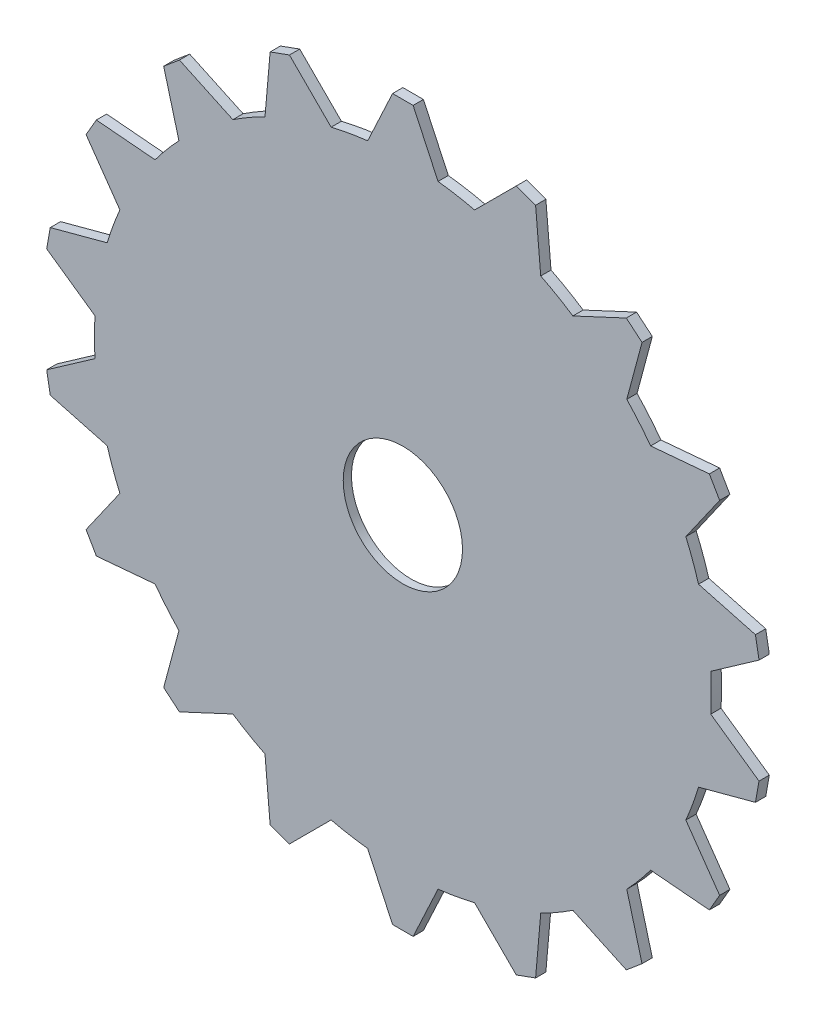
from build123d import *

# Parameters (mm, degrees)
SKETCH1_R           = 38.1
BOSS_EXTRUDE1_DEPTH = 1.27
BOSS_EXTRUDE2_DEPTH = 1.27
SKETCH3_R           = 7.366
CUT_EXTRUDE1_DEPTH  = 10
CIRPATTERN1_COUNT   = 18
SKETCH4_R           = 25.4
CUT_EXTRUDE2_DEPTH  = 0.254


with BuildPart() as part:
    # Sketch1 → Boss-Extrude1 (new body)
    with BuildSketch(Plane.XY):
        Circle(SKETCH1_R)
    extrude(amount=BOSS_EXTRUDE1_DEPTH)

    # Sketch2 → Boss-Extrude2 (add)
    with BuildSketch(Plane.XY.offset(1.27)):
        with BuildLine():
            Line((-1.27, 44.45), (1.27, 44.45))
            Line((1.27, 44.45), (4.347073366, 37.851194871))
            ThreePointArc((4.347073366, 37.851194871), (0, 38.1), (-4.347073366, 37.851194871))
            Line((-4.347073366, 37.851194871), (-1.27, 44.45))
        make_face()
    boss_extrude2 = extrude(amount=-BOSS_EXTRUDE2_DEPTH)

    # Sketch3 → Cut-Extrude1 (cut)
    with BuildSketch(Plane(origin=(0, 0, 0), x_dir=(-1, 0, 0), z_dir=(0, 0, -1))):
        Circle(SKETCH3_R)
    extrude(amount=-CUT_EXTRUDE1_DEPTH, mode=Mode.SUBTRACT)

    # CirPattern1: Boss-Extrude2 ×18 about axis
    cirpattern1_axis = Axis((0, 0, 0), (0, 0, 1))
    for i in range(1, CIRPATTERN1_COUNT):
        add(boss_extrude2.rotate(cirpattern1_axis, i * 360 / CIRPATTERN1_COUNT))

    # Sketch4 → Cut-Extrude2 (cut)
    with BuildSketch(Plane(origin=(0, 0, 0), x_dir=(-1, 0, 0), z_dir=(0, 0, -1))):
        Circle(SKETCH4_R)
    extrude(amount=-CUT_EXTRUDE2_DEPTH, mode=Mode.SUBTRACT)


solid = part.part
